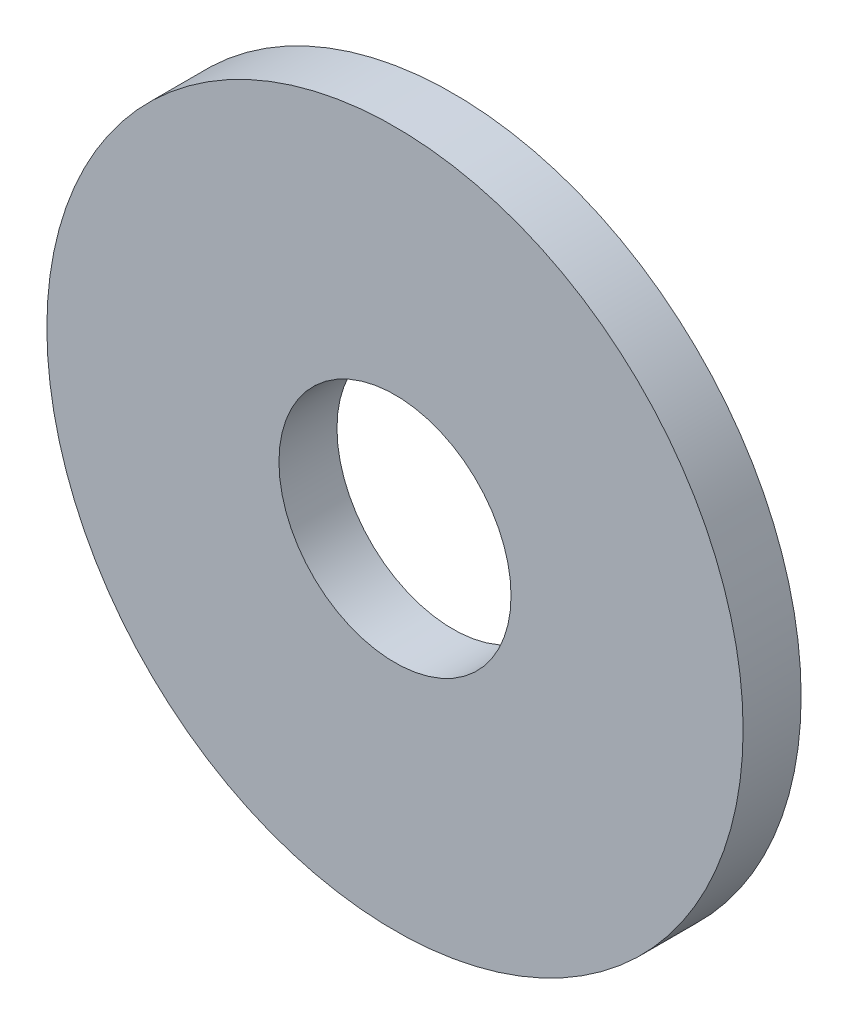
from build123d import *

# Parameters (mm, degrees)
ESQUISSE1_R        = 6
ESQUISSE1_R_2      = 2
BOSS_EXTRU_1_DEPTH = 1


with BuildPart() as part:
    # Esquisse1 → Boss.-Extru.1 (new body)
    with BuildSketch(Plane.XY):
        Circle(ESQUISSE1_R)
        Circle(ESQUISSE1_R_2, mode=Mode.SUBTRACT)
    extrude(amount=BOSS_EXTRU_1_DEPTH)


solid = part.part
